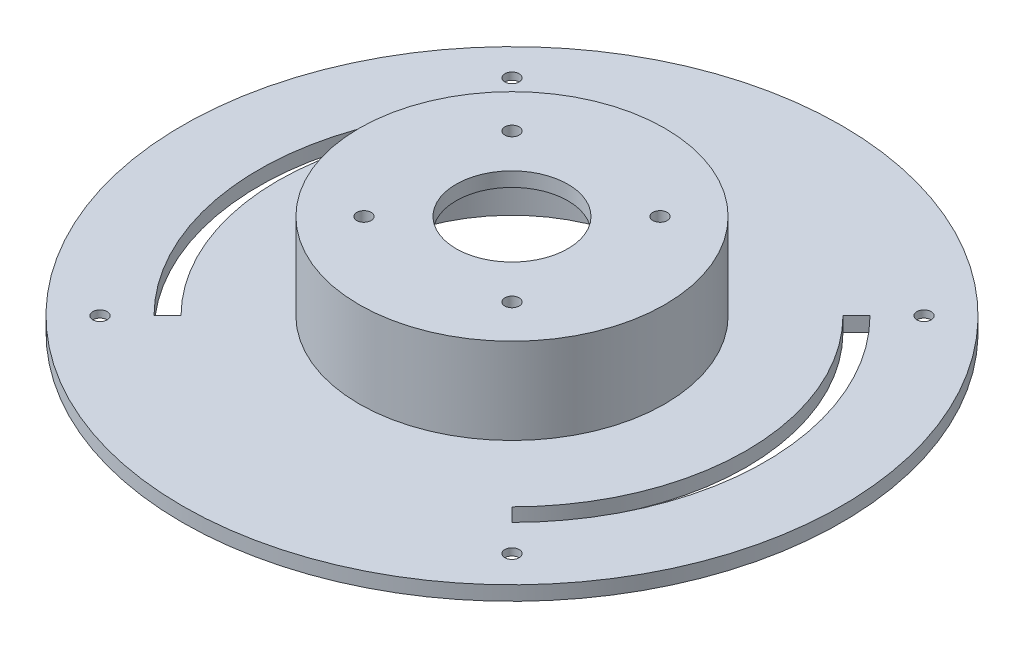
from build123d import *

# Parameters (mm, degrees)
SKETCH1_R           = 69
BOSS_EXTRUDE1_DEPTH = 3
SKETCH2_R           = 32
BOSS_EXTRUDE2_DEPTH = 18
SKETCH3_R           = 11.7
SKETCH3_R_2         = 1.5
CUT_EXTRUDE1_DEPTH  = 22
SKETCH6_R           = 30
CUT_EXTRUDE3_DEPTH  = 18
SKETCH7_R           = 1.5
CUT_EXTRUDE5_DEPTH  = 4
SKETCH8_R           = 4.05
CUT_EXTRUDE6_DEPTH  = 1.5


with BuildPart() as part:
    # Sketch1 → Boss-Extrude1 (new body)
    with BuildSketch(Plane(origin=(0, 0, 0), x_dir=(1, 0, 0), z_dir=(0, 1, 0))):
        Circle(SKETCH1_R)
    extrude(amount=BOSS_EXTRUDE1_DEPTH)

    # Sketch2 → Boss-Extrude2 (add)
    with BuildSketch(Plane(origin=(0, 3, 0), x_dir=(1, 0, 0), z_dir=(0, 1, 0))):
        Circle(SKETCH2_R)
    extrude(amount=BOSS_EXTRUDE2_DEPTH)

    # Sketch3 → Cut-Extrude1 (cut, through all)
    with BuildSketch(Plane(origin=(0, 21, 0), x_dir=(1, 0, 0), z_dir=(0, 1, 0))):
        Circle(SKETCH3_R)
        with Locations((15.5, 15.5)):
            Circle(SKETCH3_R_2)
        with Locations((-15.5, 15.5)):
            Circle(SKETCH3_R_2)
        with Locations((15.5, -15.5)):
            Circle(SKETCH3_R_2)
        with Locations((-15.5, -15.5)):
            Circle(SKETCH3_R_2)
    extrude(amount=-CUT_EXTRUDE1_DEPTH, mode=Mode.SUBTRACT)

    # Sketch6 → Cut-Extrude3 (cut)
    with BuildSketch(Plane(origin=(0, 0, 0), x_dir=(-1, 0, 0), z_dir=(0, -1, 0))):
        Circle(SKETCH6_R)
    extrude(amount=-CUT_EXTRUDE3_DEPTH, mode=Mode.SUBTRACT)

    # Sketch7 → Cut-Extrude5 (cut, through all)
    with BuildSketch(Plane(origin=(0, 3, 0), x_dir=(1, 0, 0), z_dir=(0, 1, 0))):
        with Locations((43.133513652, 43.133513652)):
            Circle(SKETCH7_R)
        with Locations((43.133513652, -43.133513652)):
            Circle(SKETCH7_R)
        with Locations((-43.133513652, -43.133513652)):
            Circle(SKETCH7_R)
        with Locations((-43.133513652, 43.133513652)):
            Circle(SKETCH7_R)
        with BuildLine():
            Line((34.648232278, 34.648232278), (37.476659403, 37.476659403))
            ThreePointArc((37.476659403, 37.476659403), (53, 0), (37.476659403, -37.476659403))
            Line((37.476659403, -37.476659403), (34.648232278, -34.648232278))
            ThreePointArc((34.648232278, -34.648232278), (49, 0), (34.648232278, 34.648232278))
        make_face()
        with BuildLine():
            Line((-37.476659403, -37.476659403), (-34.648232278, -34.648232278))
            ThreePointArc((-34.648232278, -34.648232278), (-49, 0), (-34.648232278, 34.648232278))
            Line((-34.648232278, 34.648232278), (-37.476659403, 37.476659403))
            ThreePointArc((-37.476659403, 37.476659403), (-53, 0), (-37.476659403, -37.476659403))
        make_face()
    extrude(amount=-CUT_EXTRUDE5_DEPTH, mode=Mode.SUBTRACT)

    # Sketch8 → Cut-Extrude6 (cut)
    with BuildSketch(Plane.XZ):
        with Locations((-43.133513652, 43.133513652)):
            Circle(SKETCH8_R)
        with Locations((43.133513652, 43.133513652)):
            Circle(SKETCH8_R)
        with Locations((43.133513652, -43.133513652)):
            Circle(SKETCH8_R)
        with Locations((-43.133513652, -43.133513652)):
            Circle(SKETCH8_R)
    extrude(amount=-CUT_EXTRUDE6_DEPTH, mode=Mode.SUBTRACT)


solid = part.part
